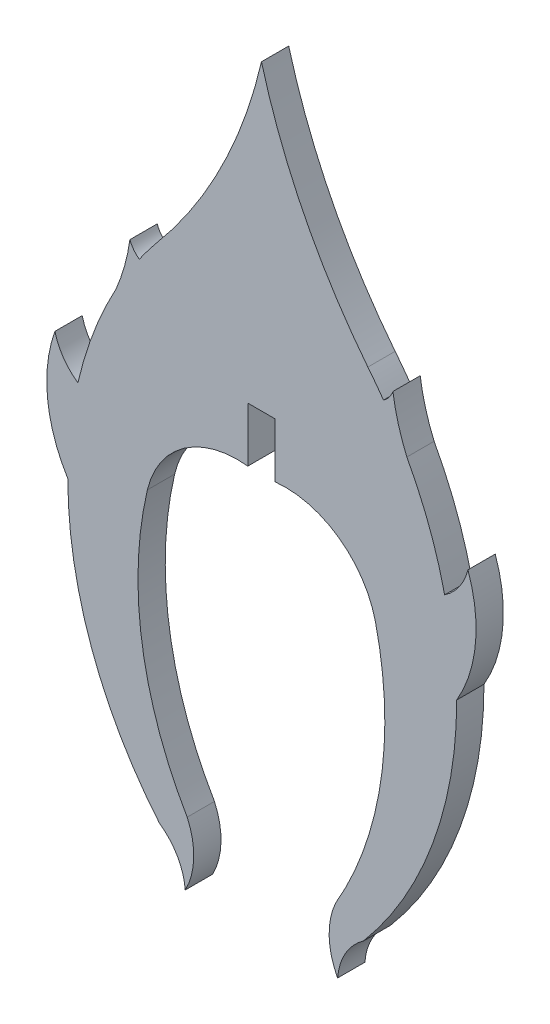
from build123d import *

# Parameters (mm, degrees)
BOSS_EXTRUDE1_DEPTH = 1.524


with BuildPart() as part:
    # Sketch1 → Boss-Extrude1 (new body)
    with BuildSketch(Plane.XY):
        with BuildLine():
            Line((-0.762799401, 4.151739841), (0.763181799, 4.152733255))
            Line((0.763181799, 4.152733255), (0.763181799, 1.101764269))
            ThreePointArc((0.763181799, 1.101764269), (4.319640518, 0.186449021), (6.371385502, -2.859292784))
            ThreePointArc((6.371385502, -2.859292784), (6.672574584, -10.435641577), (4.151071361, -17.586431561))
            ThreePointArc((4.151071361, -17.586431561), (3.785308505, -19.389837846), (4.258503872, -21.168079349))
            ThreePointArc((4.258503872, -21.168079349), (4.695327747, -19.753303526), (5.694864831, -18.660906461))
            ThreePointArc((5.694864831, -18.660906461), (9.578008584, -11.987204881), (10.914606675, -4.382561317))
            ThreePointArc((10.914606675, -4.382561317), (11.963687789, -1.143514723), (11.54368289, 2.235181758))
            ThreePointArc((11.54368289, 2.235181758), (11.063913724, 1.182736218), (10.240953414, 0.369990013))
            ThreePointArc((10.240953414, 0.369990013), (9.378846201, 3.251271559), (8.129251062, 5.986874633))
            ThreePointArc((8.129251062, 5.986874633), (7.646964471, 7.353540521), (7.350228625, 8.772104529))
            ThreePointArc((7.350228625, 8.772104529), (7.140948693, 8.388008696), (6.822386333, 8.088265938))
            ThreePointArc((6.822386333, 8.088265938), (6.395648788, 8.676833831), (5.949561914, 9.25087529))
            ThreePointArc((5.949561914, 9.25087529), (2.381070398, 14.85503863), (0.00144629, 21.058115893))
            ThreePointArc((0.00144629, 21.058115893), (-2.237613904, 14.848855853), (-5.874078491, 9.34027835))
            ThreePointArc((-5.874078491, 9.34027835), (-6.359611605, 8.722749648), (-6.822768731, 8.088265938))
            ThreePointArc((-6.822768731, 8.088265938), (-7.141331091, 8.388008696), (-7.350611023, 8.772104529))
            ThreePointArc((-7.350611023, 8.772104529), (-7.647346869, 7.353540521), (-8.12963346, 5.986874633))
            ThreePointArc((-8.12963346, 5.986874633), (-9.386584799, 3.258077765), (-10.259685397, 0.383368325))
            ThreePointArc((-10.259685397, 0.383368325), (-11.070398481, 1.192598639), (-11.54368289, 2.235724362))
            ThreePointArc((-11.54368289, 2.235724362), (-11.954593886, -1.23311659), (-10.820946706, -4.537136787))
            ThreePointArc((-10.820946706, -4.537136787), (-9.502375995, -12.050586646), (-5.695247229, -18.660906461))
            ThreePointArc((-5.695247229, -18.660906461), (-4.695710145, -19.753303526), (-4.25888627, -21.168079349))
            ThreePointArc((-4.25888627, -21.168079349), (-3.785690903, -19.389837846), (-4.151453759, -17.586431561))
            ThreePointArc((-4.151453759, -17.586431561), (-6.675465031, -10.434527086), (-6.375410647, -2.856246417))
            ThreePointArc((-6.375410647, -2.856246417), (-4.320748698, 0.188135712), (-0.762909272, 1.100098915))
            Line((-0.762909272, 1.100098915), (-0.762799401, 4.151739841))
        make_face()
    extrude(amount=BOSS_EXTRUDE1_DEPTH)


solid = part.part
